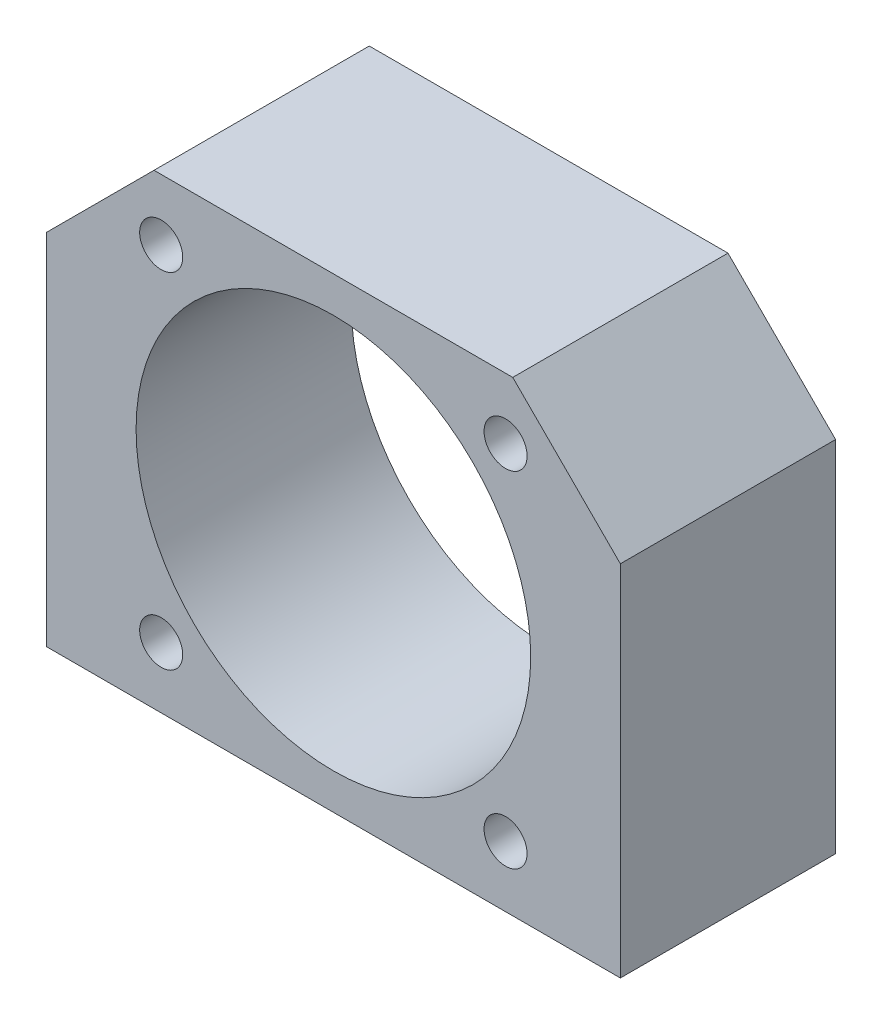
from build123d import *

# Parameters (mm, degrees)
SZKIC1_W                    = 80
SZKIC1_H                    = 65
DODANIE_WYCI_GNI_CIE1_DEPTH = 30
SZKIC2_R                    = 27.5
WYTNIJ_WYCI_GNI_CIE1_DEPTH  = 30
SZKIC4_R                    = 3
WYTNIJ_WYCI_GNI_CIE2_DEPTH  = 30
SFAZOWANIE1_SIZE            = 15
SZKIC6_R                    = 3
WYTNIJ_WYCI_GNI_CIE3_DEPTH  = 25
SZKIC8_R                    = 5
WYTNIJ_WYCI_GNI_CIE5_DEPTH  = 6


with BuildPart() as part:
    # Szkic1 → Dodanie-wyciągnięcie1 (new body)
    with BuildSketch(Plane.XY):
        Rectangle(SZKIC1_W, SZKIC1_H)
    extrude(amount=DODANIE_WYCI_GNI_CIE1_DEPTH)

    # Szkic2 → Wytnij-wyciągnięcie1 (cut)
    with BuildSketch(Plane.XY.offset(30)):
        Circle(SZKIC2_R)
    extrude(amount=-WYTNIJ_WYCI_GNI_CIE1_DEPTH, mode=Mode.SUBTRACT)

    # Szkic4 → Wytnij-wyciągnięcie2 (cut)
    with BuildSketch(Plane.XY.offset(30)):
        with Locations((-24, 24)):
            Circle(SZKIC4_R)
        with Locations((24, 24)):
            Circle(SZKIC4_R)
        with Locations((-24, -24)):
            Circle(SZKIC4_R)
        with Locations((24, -24)):
            Circle(SZKIC4_R)
    extrude(amount=-WYTNIJ_WYCI_GNI_CIE2_DEPTH, mode=Mode.SUBTRACT)

    # Sfazowanie1
    sfazowanie1_edges = [part.edges().sort_by_distance(p)[0] for p in [
        (-40, 32.5, 15),
        (40, 32.5, 15),
    ]]
    chamfer(sfazowanie1_edges, length=SFAZOWANIE1_SIZE)

    # Szkic6 → Wytnij-wyciągnięcie3 (cut)
    with BuildSketch(Plane.XZ.offset(32.5)):
        with Locations((-33, 23)):
            Circle(SZKIC6_R)
        with Locations((33, 23)):
            Circle(SZKIC6_R)
        with Locations((33, 7)):
            Circle(SZKIC6_R)
        with Locations((-33, 7)):
            Circle(SZKIC6_R)
    extrude(amount=-WYTNIJ_WYCI_GNI_CIE3_DEPTH, mode=Mode.SUBTRACT)

    # Szkic8 → Wytnij-wyciągnięcie5 (cut)
    with BuildSketch(Plane(origin=(0, 0, 0), x_dir=(-1, 0, 0), z_dir=(0, 0, -1))):
        with Locations((24, -24)):
            Circle(SZKIC8_R)
        with Locations((-24, -24)):
            Circle(SZKIC8_R)
        with Locations((-24, 24)):
            Circle(SZKIC8_R)
        with Locations((24, 24)):
            Circle(SZKIC8_R)
    extrude(amount=-WYTNIJ_WYCI_GNI_CIE5_DEPTH, mode=Mode.SUBTRACT)


solid = part.part
